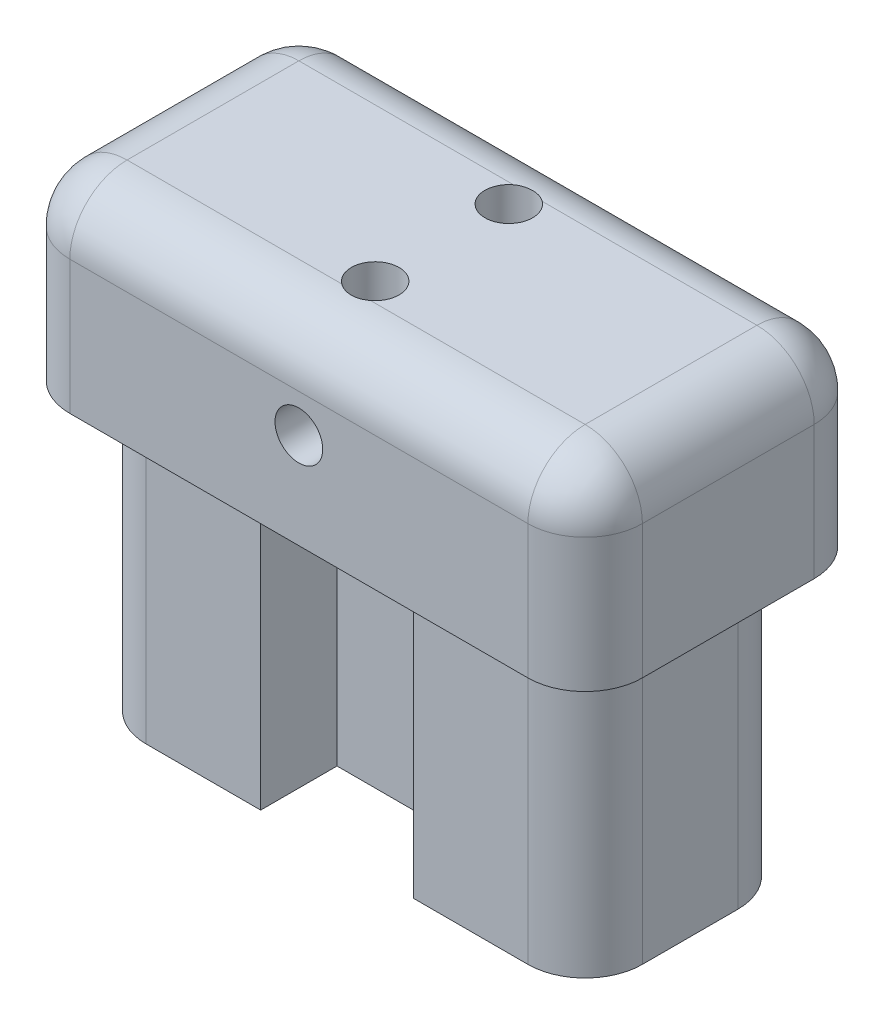
from build123d import *

# Parameters (mm, degrees)
SKETCH1_W           = 30
SKETCH1_H           = 15
BOSS_EXTRUDE1_DEPTH = 10
BOSS_EXTRUDE2_DEPTH = 15
FILLET1_R           = 3
SKETCH3_R           = 1.25
CUT_EXTRUDE1_DEPTH  = 11
SKETCH4_R           = 1.25
CUT_EXTRUDE2_DEPTH  = 16.0000001


with BuildPart() as part:
    # Sketch1 → Boss-Extrude1 (new body)
    with BuildSketch(Plane(origin=(0, 0, 0), x_dir=(1, 0, 0), z_dir=(0, 1, 0))):
        Rectangle(SKETCH1_W, SKETCH1_H)
    extrude(amount=BOSS_EXTRUDE1_DEPTH)

    # Sketch2 → Boss-Extrude2 (add)
    with BuildSketch(Plane.XZ):
        Polygon((-13, -5.5), (-4, -5.5), (-4, -1.5), (4, -1.5), (4, -5.5), (13, -5.5), (13, 5.5), (4, 5.5), (4, 1.5), (-4, 1.5), (-4, 5.5), (-13, 5.5), align=None)
    extrude(amount=BOSS_EXTRUDE2_DEPTH)

    # Fillet1
    fillet1_edges = [part.edges().sort_by_distance(p)[0] for p in [
        (-15, 10, 0),
        (0, 10, 7.5),
        (13, -7.5, 5.5),
        (-13, -7.5, 5.5),
        (-13, -7.5, -5.5),
        (13, -7.5, -5.5),
        (15, 10, 0),
        (15, 5, 7.5),
        (-15, 5, 7.5),
        (-15, 5, -7.5),
        (15, 5, -7.5),
        (0, 10, -7.5),
    ]]
    fillet(fillet1_edges, radius=FILLET1_R)

    # Sketch3 → Cut-Extrude1 (cut, through all)
    with BuildSketch(Plane.XZ):
        with Locations((0, 3.5)):
            Circle(SKETCH3_R)
        with Locations((0, -3.5)):
            Circle(SKETCH3_R)
    extrude(amount=-CUT_EXTRUDE1_DEPTH, mode=Mode.SUBTRACT)

    # Sketch4 → Cut-Extrude2 (cut, through all)
    with BuildSketch(Plane.XY.offset(7.5)):
        with Locations((0, 5)):
            Circle(SKETCH4_R)
    extrude(amount=-CUT_EXTRUDE2_DEPTH, mode=Mode.SUBTRACT)


solid = part.part
